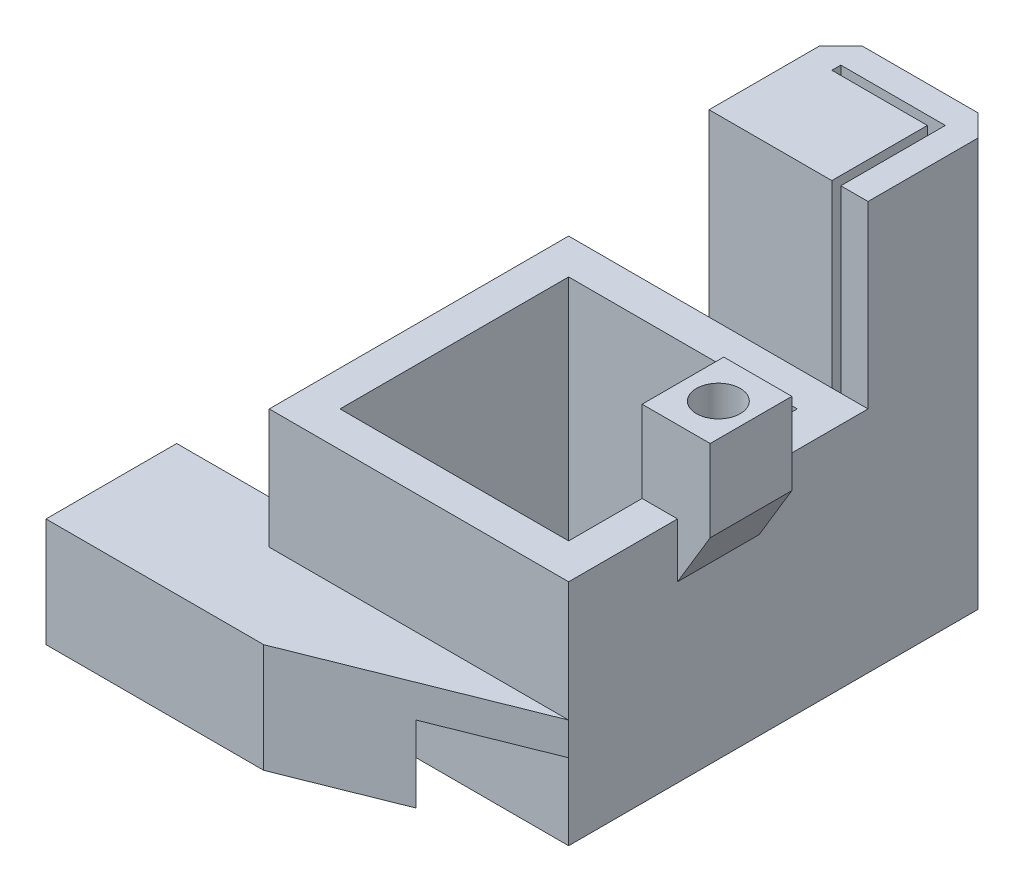
from build123d import *

# Parameters (mm, degrees)
SKETCH1_W           = 55
SKETCH1_H           = 55
SKETCH1_W_2         = 42
SKETCH1_H_2         = 42
BOSS_EXTRUDE1_DEPTH = 42
SKETCH2_W           = 25
SKETCH2_H           = 8
BOSS_EXTRUDE2_DEPTH = 20
BOSS_EXTRUDE3_DEPTH = 75
SKETCH5_W           = 12.5
SKETCH5_H           = 15
SKETCH5_R           = 4.025
BOSS_EXTRUDE4_DEPTH = 15
BOSS_EXTRUDE5_DEPTH = 15
SKETCH7_W           = 8.01
SKETCH7_H           = 6
BOSS_EXTRUDE6_DEPTH = 37.46
SKETCH8_W           = 8.01
SKETCH8_H           = 14
CUT_EXTRUDE1_DEPTH  = 49.54
SKETCH9_W           = 47
SKETCH9_H           = 4
BOSS_EXTRUDE7_DEPTH = 10


with BuildPart() as part:
    # Sketch1 → Boss-Extrude1 (new body)
    with BuildSketch(Plane(origin=(0, 0, 0), x_dir=(1, 0, 0), z_dir=(0, 1, 0))):
        with Locations((21, 21)):
            Rectangle(SKETCH1_W, SKETCH1_H)
        with Locations((21, 21)):
            Rectangle(SKETCH1_W_2, SKETCH1_H_2, mode=Mode.SUBTRACT)
    extrude(amount=BOSS_EXTRUDE1_DEPTH)

    # Sketch2 → Boss-Extrude2 (add)
    with BuildSketch(Plane.XZ):
        Polygon((5.96, 6.5), (5.96, 14.51), (-31.5, 14.51), (-31.5, 22.51), (8.5, 22.51), (48.5, 6.5), align=None)
        with Locations((-19, 2.5)):
            Rectangle(SKETCH2_W, SKETCH2_H)
    extrude(amount=-BOSS_EXTRUDE2_DEPTH)

    # Sketch3 → Boss-Extrude3 (add)
    with BuildSketch(Plane.XZ):
        Polygon((48.5, -68.7), (48.5, -48.5), (43.5, -48.5), (43.5, -67.7), (24.3, -67.7), (24.3, -66.05), (41.85, -66.05), (41.85, -48.5), (19.3, -48.5), (19.3, -68.7), (23.3, -72.7), (44.5, -72.7), align=None)
    extrude(amount=-BOSS_EXTRUDE3_DEPTH)

    # Sketch5 → Boss-Extrude4 (add)
    with BuildSketch(Plane(origin=(0, 42, 0), x_dir=(1, 0, 0), z_dir=(0, 1, 0))):
        with Locations((48.25, 21)):
            Rectangle(SKETCH5_W, SKETCH5_H)
        with Locations((48.5, 21)):
            Circle(SKETCH5_R, mode=Mode.SUBTRACT)
    extrude(amount=BOSS_EXTRUDE4_DEPTH)

    # Sketch6 → Boss-Extrude5 (add)
    with BuildSketch(Plane.XY.offset(-13.5)):
        Polygon((54.5, 42), (48.5, 42), (48.5, 32), align=None)
    extrude(amount=-BOSS_EXTRUDE5_DEPTH)

    # Sketch7 → Boss-Extrude6 (add)
    with BuildSketch(Plane.ZY.offset(-5.96)):
        with Locations((10.505, 17)):
            Rectangle(SKETCH7_W, SKETCH7_H)
    extrude(amount=BOSS_EXTRUDE6_DEPTH)

    # Sketch8 → Cut-Extrude1 (cut, through all)
    with BuildSketch(Plane.ZY.offset(-5.96)):
        with Locations((10.505, 7)):
            Rectangle(SKETCH8_W, SKETCH8_H)
    extrude(amount=-CUT_EXTRUDE1_DEPTH, mode=Mode.SUBTRACT)

    # Sketch9 → Boss-Extrude7 (add)
    with BuildSketch(Plane.ZY.offset(6.5)):
        with Locations((-25, 2)):
            Rectangle(SKETCH9_W, SKETCH9_H)
    extrude(amount=BOSS_EXTRUDE7_DEPTH)


solid = part.part
